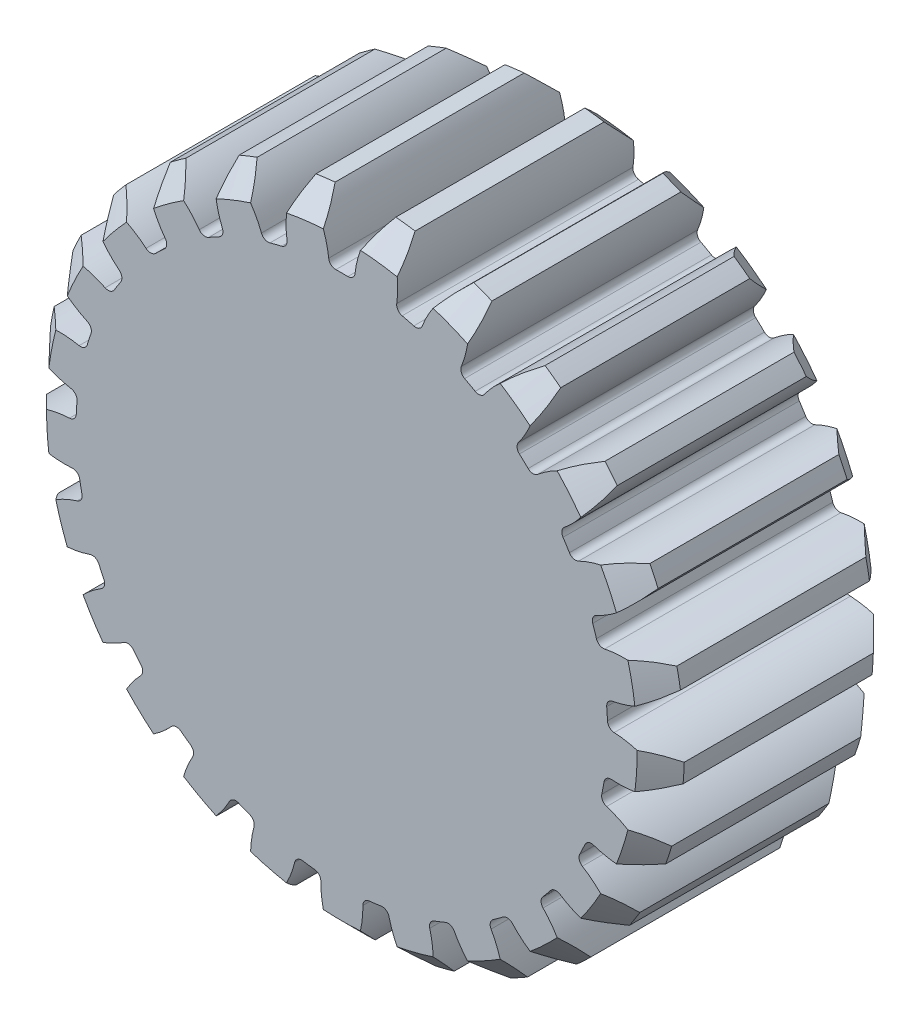
from build123d import *

# Parameters (mm, degrees)
SKETCH1_R                = 27
BOSS_EXTRUDE1_DEPTH      = 10
CUT_EXTRUDE1_DEPTH       = 11
FILLET1_R                = 0.6
CHAMFER1_SIZE            = 2
CIRPATTERN1_COUNT        = 25
FILLET1_OF_CIRPATTERN1_R = 0.6


with BuildPart() as part:
    # Sketch1 → Boss-Extrude1 (new body, symmetric)
    with BuildSketch(Plane.XY):
        Circle(SKETCH1_R)
    extrude(amount=BOSS_EXTRUDE1_DEPTH, both=True)

    # Sketch2 → Cut-Extrude1 (cut, symmetric)
    with BuildSketch(Plane.XY):
        with BuildLine():
            ThreePointArc((2.569085244, 26.877496182), (1.510220721, 24.781486697), (1.072022538, 22.474446994))
            ThreePointArc((1.072022538, 22.474446994), (0, 22.5), (-1.072022538, 22.474446994))
            ThreePointArc((-1.072022538, 22.474446994), (-1.510220721, 24.781486697), (-2.569085244, 26.877496182))
            ThreePointArc((-2.569085244, 26.877496182), (0, 27), (2.569085244, 26.877496182))
        make_face()
    cut_extrude1 = extrude(amount=CUT_EXTRUDE1_DEPTH, both=True, mode=Mode.SUBTRACT)

    # Fillet1
    fillet1_edges = [part.edges().sort_by_distance(p)[0] for p in [
        (1.072022538, 22.474446994, 0),
        (-1.072022538, 22.474446994, 0),
    ]]
    fillet(fillet1_edges, radius=FILLET1_R)

    # Chamfer1
    chamfer1_edges = [part.edges().sort_by_distance(p)[0] for p in [
        (0, -27, -10),
        (0, -27, 10),
    ]]
    chamfer(chamfer1_edges, length=CHAMFER1_SIZE)

    # CirPattern1: Cut-Extrude1 ×25 about axis
    cirpattern1_axis = Axis((0, 0, 0), (0, 0, 1))
    for i in range(1, CIRPATTERN1_COUNT):
        add(cut_extrude1.rotate(cirpattern1_axis, i * 360 / CIRPATTERN1_COUNT), mode=Mode.SUBTRACT)

    # Fillet1 of CirPattern1
    fillet1_of_cirpattern1_edges = [part.edges().sort_by_distance(p)[0] for p in [
        (-4.550824708, 22.034972078, 0),
        (-6.627510666, 21.50176975, 0),
        (-9.887726902, 20.210958827, 0),
        (-11.766567924, 19.178057235, 0),
        (-14.603346849, 17.117016703, 0),
        (-16.166288445, 15.649316851, 0),
        (-18.401384806, 12.947549467, 0),
        (-19.550221608, 11.137272336, 0),
        (-21.043196081, 7.964540081, 0),
        (-21.705742446, 5.92543204, 0),
        (-22.362785954, 2.481089349, 0),
        (-22.497411659, 0.341275057, 0),
        (-22.277239742, -3.158257351, 0),
        (-21.875485757, -5.264325494, 0),
        (-20.791932626, -8.599159126, 0),
        (-19.879042632, -10.539149113, 0),
        (-18.000191916, -13.499744108, 0),
        (-16.63352615, -15.151759232, 0),
        (-14.077432948, -17.552090519, 0),
        (-12.342864045, -18.812328595, 0),
        (-9.270137095, -20.501574531, 0),
        (-7.276654398, -21.290850165, 0),
        (-3.880364434, -22.162869215, 0),
        (-1.753225794, -22.431589318, 0),
        (1.753225794, -22.431589318, 0),
        (3.880364434, -22.162869215, 0),
        (7.276654398, -21.290850165, 0),
        (9.270137095, -20.501574531, 0),
        (12.342864045, -18.812328595, 0),
        (14.077432948, -17.552090519, 0),
        (16.63352615, -15.151759232, 0),
        (18.000191916, -13.499744108, 0),
        (19.879042632, -10.539149113, 0),
        (20.791932626, -8.599159126, 0),
        (21.875485757, -5.264325494, 0),
        (22.277239742, -3.158257351, 0),
        (22.497411659, 0.341275057, 0),
        (22.362785954, 2.481089349, 0),
        (21.705742446, 5.92543204, 0),
        (21.043196081, 7.964540081, 0),
        (19.550221608, 11.137272336, 0),
        (18.401384806, 12.947549467, 0),
        (16.166288445, 15.649316851, 0),
        (14.603346849, 17.117016703, 0),
        (11.766567924, 19.178057235, 0),
        (9.887726902, 20.210958827, 0),
        (6.627510666, 21.50176975, 0),
        (4.550824708, 22.034972078, 0),
    ]]
    fillet(fillet1_of_cirpattern1_edges, radius=FILLET1_OF_CIRPATTERN1_R)


solid = part.part
